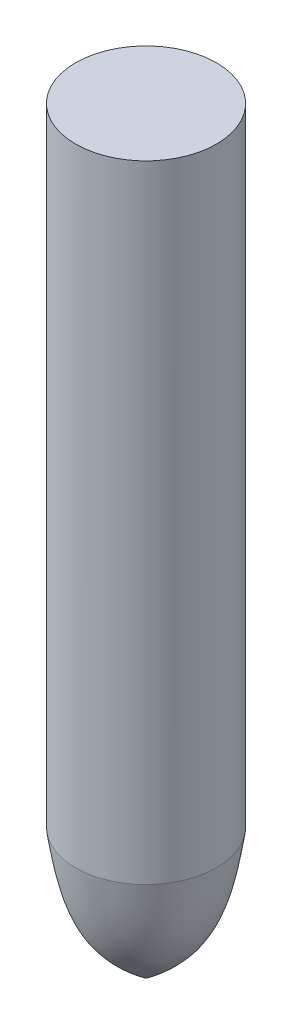
from build123d import *

# Parameters (mm, degrees)
SKETCH1_R      = 70
EXTRUDE1_DEPTH = 375


with BuildPart() as part:
    # Sketch1 → Extrude1 (new body, symmetric)
    with BuildSketch(Plane(origin=(0, 0, 0), x_dir=(1, 0, 0), z_dir=(0, 1, 0))):
        with Locations(Location((0, 0, 0), (0, 0, 270))):  # turned: the seam where the file's is
            Circle(SKETCH1_R)
    extrude(amount=EXTRUDE1_DEPTH, both=True)

    # Sketch2 → Cut-Revolve1 (revolve, cut)
    with BuildSketch(Plane.XY, mode=Mode.PRIVATE) as cut_revolve1_sk:
        with BuildLine():
            Line((-70, -247.794305726), (-139.12869609, -247.794305726))
            Line((-139.12869609, -247.794305726), (-117.349403122, -403.920416703))
            Line((-117.349403122, -403.920416703), (0, -421.379639628))
            Line((0, -421.379639628), (0, -377.971198962))
            add(Edge.make_bspline(
                [(0, -377.971198962), (-15.769115632, -365.472402654), (-56.753696333, -332.987516507), (-64.954509419, -280.244229372), (-70, -247.794305726)],
                knots=[0, 0, 0, 0, 0.384757276, 1, 1, 1, 1], degree=3))
        make_face()
    revolve(cut_revolve1_sk.sketch.rotate(Axis((0, -315.550160193, 0), (0, 1, 0)), 270), axis=Axis((0, -315.550160193, 0), (0, 1, 0)), mode=Mode.SUBTRACT)  # turned: the seam where the file's is


solid = part.part
